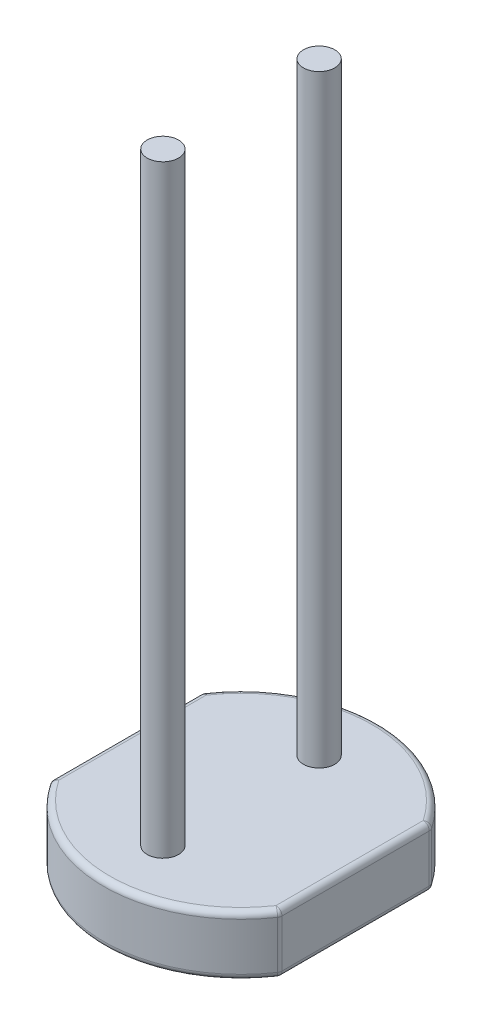
from build123d import *

# Parameters (mm, degrees)
BOSS_EXTRUDE1_DEPTH      = 1
SKETCH2_R                = 0.26
BOSS_EXTRUDE2_DEPTH      = 10
BOSS_EXTRUDE2_DEPTH_BACK = 1.1
CUT_EXTRUDE1_DEPTH       = 0.01
FILLET1_R                = 0.1


with BuildPart() as part:
    # Sketch1 → Boss-Extrude1 (new body)
    with BuildSketch(Plane(origin=(0, 0, 0), x_dir=(1, 0, 0), z_dir=(0, 1, 0))):
        with BuildLine():
            Line((-1.9, 1.251249376), (-1.9, -1.251249376))
            ThreePointArc((-1.9, -1.251249376), (0, -2.275), (1.9, -1.251249376))
            Line((1.9, -1.251249376), (1.9, 1.251249376))
            ThreePointArc((1.9, 1.251249376), (0, 2.275), (-1.9, 1.251249376))
        make_face()
    extrude(amount=BOSS_EXTRUDE1_DEPTH)

    # Sketch2 → Boss-Extrude2 (add, two sides)
    with BuildSketch(Plane(origin=(0, 1, 0), x_dir=(1, 0, 0), z_dir=(0, 1, 0))) as boss_extrude2_sk:
        with Locations((0, 1.295)):
            Circle(SKETCH2_R)
        with Locations((0, -1.295)):
            Circle(SKETCH2_R)
    extrude(amount=BOSS_EXTRUDE2_DEPTH)
    extrude(boss_extrude2_sk.sketch, amount=-BOSS_EXTRUDE2_DEPTH_BACK)

    # Sketch4 → Cut-Extrude1 (cut)
    with BuildSketch(Plane.XZ):
        with BuildLine():
            Line((1.9, -1.251249376), (1.9, 1.251249376))
            ThreePointArc((1.9, 1.251249376), (0, 2.275), (-1.9, 1.251249376))
            Line((-1.9, 1.251249376), (-1.9, -1.251249376))
            ThreePointArc((-1.9, -1.251249376), (0, -2.275), (1.9, -1.251249376))
        make_face()
        with BuildLine():
            Line((-1.4, 1.091157642), (-1.4, -1.091157642))
            ThreePointArc((-1.4, -1.091157642), (0, -1.775), (1.4, -1.091157642))
            Line((1.4, -1.091157642), (1.4, 1.091157642))
            ThreePointArc((1.4, 1.091157642), (1.375341403, 1.122078885), (1.35, 1.152443057))
            Line((1.35, 1.152443057), (1.35, -1))
            ThreePointArc((1.35, -1), (1.2, -1.15), (1.05, -1))
            Line((1.05, -1), (1.05, 0.9))
            ThreePointArc((1.05, 0.9), (0.9, 1.05), (0.75, 0.9))
            Line((0.75, 0.9), (0.75, -0.9))
            ThreePointArc((0.75, -0.9), (0.6, -1.05), (0.45, -0.9))
            Line((0.45, -0.9), (0.45, 0.7))
            ThreePointArc((0.45, 0.7), (0.3, 0.85), (0.15, 0.7))
            Line((0.15, 0.7), (0.15, -0.75))
            ThreePointArc((0.15, -0.75), (0, -0.9), (-0.15, -0.75))
            Line((-0.15, -0.75), (-0.15, 0.7))
            ThreePointArc((-0.15, 0.7), (-0.3, 0.85), (-0.45, 0.7))
            Line((-0.45, 0.7), (-0.45, -0.9))
            ThreePointArc((-0.45, -0.9), (-0.6, -1.05), (-0.75, -0.9))
            Line((-0.75, -0.9), (-0.75, 0.9))
            ThreePointArc((-0.75, 0.9), (-0.9, 1.05), (-1.05, 0.9))
            Line((-1.05, 0.9), (-1.05, -1))
            ThreePointArc((-1.05, -1), (-1.2, -1.15), (-1.35, -1))
            Line((-1.35, -1), (-1.35, 1.152443057))
            ThreePointArc((-1.35, 1.152443057), (-1.375341403, 1.122078885), (-1.4, 1.091157642))
        make_face(mode=Mode.SUBTRACT)
        with BuildLine():
            Line((1.25, 1.152443057), (1.25, -1))
            ThreePointArc((1.25, -1), (1.2, -1.05), (1.15, -1))
            Line((1.15, -1), (1.15, 0.9))
            ThreePointArc((1.15, 0.9), (0.9, 1.15), (0.65, 0.9))
            Line((0.65, 0.9), (0.65, -0.9))
            ThreePointArc((0.65, -0.9), (0.6, -0.95), (0.55, -0.9))
            Line((0.55, -0.9), (0.55, 0.7))
            ThreePointArc((0.55, 0.7), (0.3, 0.95), (0.05, 0.7))
            Line((0.05, 0.7), (0.05, -0.75))
            ThreePointArc((0.05, -0.75), (0.035355339, -0.785355339), (0, -0.8))
            ThreePointArc((0, -0.8), (-0.035355339, -0.785355339), (-0.05, -0.75))
            Line((-0.05, -0.75), (-0.05, 0.7))
            ThreePointArc((-0.05, 0.7), (-0.3, 0.95), (-0.55, 0.7))
            Line((-0.55, 0.7), (-0.55, -0.9))
            ThreePointArc((-0.55, -0.9), (-0.6, -0.95), (-0.65, -0.9))
            Line((-0.65, -0.9), (-0.65, 0.9))
            ThreePointArc((-0.65, 0.9), (-0.9, 1.15), (-1.15, 0.9))
            Line((-1.15, 0.9), (-1.15, -1))
            ThreePointArc((-1.15, -1), (-1.2, -1.05), (-1.25, -1))
            Line((-1.25, -1), (-1.25, 1.152443057))
            Line((-1.25, 1.152443057), (-1.25, 1.260208316))
            ThreePointArc((-1.25, 1.260208316), (0, 1.775), (1.25, 1.260208316))
            Line((1.25, 1.260208316), (1.25, 1.152443057))
        make_face(mode=Mode.SUBTRACT)
    extrude(amount=-CUT_EXTRUDE1_DEPTH, mode=Mode.SUBTRACT)

    # Fillet1
    fillet1_edges = [part.edges().sort_by_distance(p)[0] for p in [
        (0, 1, 2.275),
        (1.9, 1, 0),
        (0, 1, -2.275),
        (0, 0.01, -2.275),
        (-1.9, 0.01, 0),
        (0, 0.01, 2.275),
        (1.9, 0.01, 0),
        (-1.9, 1, 0),
        (1.9, 0.505, -1.251249376),
        (1.9, 0.505, 1.251249376),
        (-1.9, 0.505, 1.251249376),
        (-1.9, 0.505, -1.251249376),
    ]]
    fillet(fillet1_edges, radius=FILLET1_R)


solid = part.part
